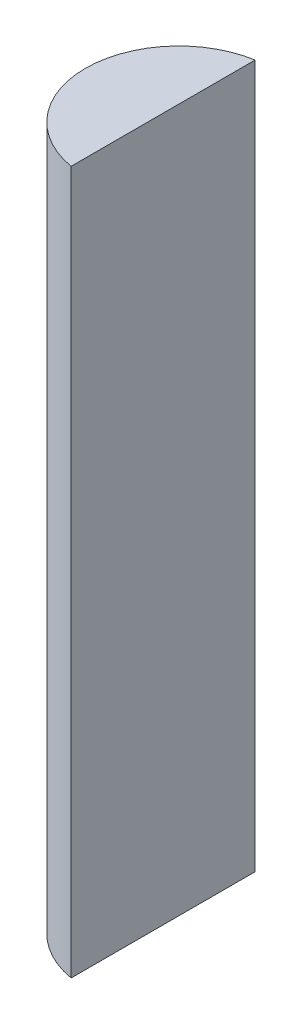
from build123d import *

# Parameters (mm, degrees)
BOSS_EXTRUDE1_DEPTH = 90


with BuildPart() as part:
    # Sketch1 → Boss-Extrude1 (new body)
    with BuildSketch(Plane(origin=(0, 0, 0), x_dir=(1, 0, 0), z_dir=(0, 1, 0))):
        with BuildLine():
            Line((-2, -11.78144728), (-2, 11.78144728))
            ThreePointArc((-2, 11.78144728), (-11.95, 0), (-2, -11.78144728))
        make_face()
    extrude(amount=BOSS_EXTRUDE1_DEPTH)


solid = part.part
